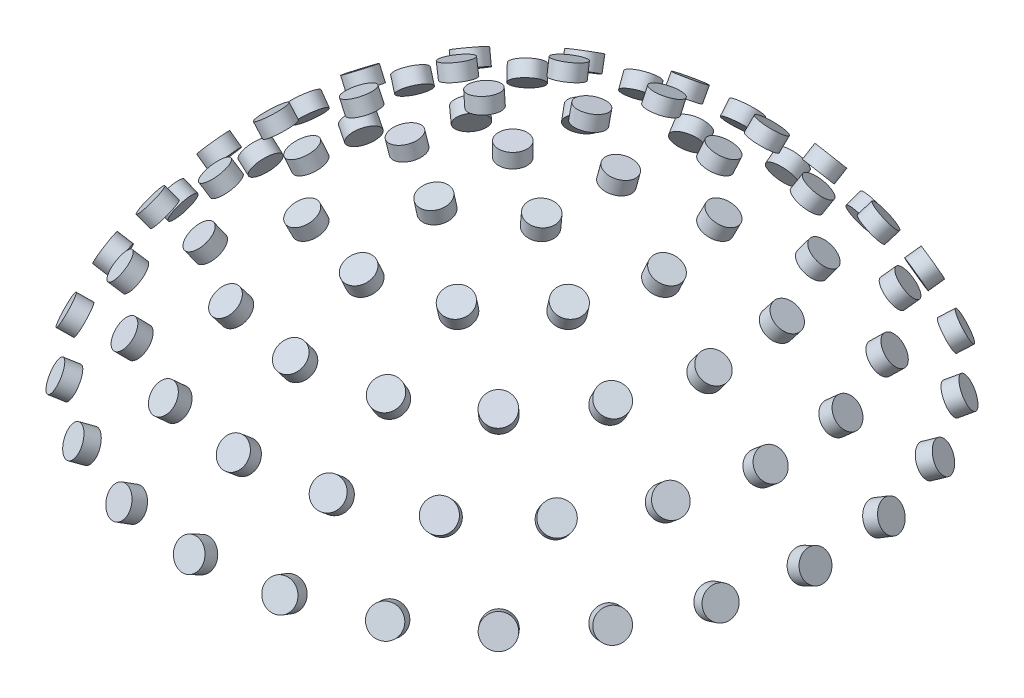
from build123d import *

# Parameters (mm, degrees)
SKETCH2_R           = 0.5
BOSS_EXTRUDE1_DEPTH = 0.5
CIRPATTERN1_COUNT   = 2
CIRPATTERN1_ANGLE   = 12.5
CIRPATTERN2_COUNT   = 2
CIRPATTERN2_ANGLE   = 25
CIRPATTERN3_COUNT   = 2
CIRPATTERN3_ANGLE   = 37.5
CIRPATTERN4_COUNT   = 2
CIRPATTERN4_ANGLE   = 50
CIRPATTERN5_COUNT   = 2
CIRPATTERN5_ANGLE   = 62.5
CIRPATTERN6_COUNT   = 6
CIRPATTERN7_COUNT   = 12
CIRPATTERN8_COUNT   = 17
CIRPATTERN9_COUNT   = 21
CIRPATTERN10_COUNT  = 25


with BuildPart() as part:
    # Sketch2 → Boss-Extrude1 (new body)
    with BuildSketch(Plane(origin=(0, 12.2, 0), x_dir=(1, 0, 0), z_dir=(0, 1, 0))):
        Circle(SKETCH2_R)
    extrude(amount=BOSS_EXTRUDE1_DEPTH)


with BuildPart() as cirpattern1_1:
    # CirPattern1: pattern copy
    add(part.part.rotate(Axis((0, 0, 0), (1, 0, 0)), 1 * CIRPATTERN1_ANGLE / (CIRPATTERN1_COUNT - 1)))


with BuildPart() as cirpattern2_1:
    # CirPattern2: pattern copy
    add(part.part.rotate(Axis((0, 0, 0), (1, 0, 0)), 1 * CIRPATTERN2_ANGLE / (CIRPATTERN2_COUNT - 1)))


with BuildPart() as cirpattern3_1:
    # CirPattern3: pattern copy
    add(part.part.rotate(Axis((0, 0, 0), (1, 0, 0)), 1 * CIRPATTERN3_ANGLE / (CIRPATTERN3_COUNT - 1)))


with BuildPart() as cirpattern4_1:
    # CirPattern4: pattern copy
    add(part.part.rotate(Axis((0, 0, 0), (1, 0, 0)), 1 * CIRPATTERN4_ANGLE / (CIRPATTERN4_COUNT - 1)))


with BuildPart() as cirpattern5_1:
    # CirPattern5: pattern copy
    add(part.part.rotate(Axis((0, 0, 0), (1, 0, 0)), 1 * CIRPATTERN5_ANGLE / (CIRPATTERN5_COUNT - 1)))


with BuildPart() as cirpattern6_1:
    # CirPattern6: pattern copy
    add(cirpattern1_1.part.rotate(Axis((0, 0, 0), (0, 1, 0)), 1 * 360 / CIRPATTERN6_COUNT))


with BuildPart() as cirpattern6_2:
    # CirPattern6: pattern copy
    add(cirpattern1_1.part.rotate(Axis((0, 0, 0), (0, 1, 0)), 2 * 360 / CIRPATTERN6_COUNT))


with BuildPart() as cirpattern6_3:
    # CirPattern6: pattern copy
    add(cirpattern1_1.part.rotate(Axis((0, 0, 0), (0, 1, 0)), 3 * 360 / CIRPATTERN6_COUNT))


with BuildPart() as cirpattern6_4:
    # CirPattern6: pattern copy
    add(cirpattern1_1.part.rotate(Axis((0, 0, 0), (0, 1, 0)), 4 * 360 / CIRPATTERN6_COUNT))


with BuildPart() as cirpattern6_5:
    # CirPattern6: pattern copy
    add(cirpattern1_1.part.rotate(Axis((0, 0, 0), (0, 1, 0)), 5 * 360 / CIRPATTERN6_COUNT))


with BuildPart() as cirpattern7_1:
    # CirPattern7: pattern copy
    add(cirpattern2_1.part.rotate(Axis((0, 0, 0), (0, 1, 0)), 1 * 360 / CIRPATTERN7_COUNT))


with BuildPart() as cirpattern7_2:
    # CirPattern7: pattern copy
    add(cirpattern2_1.part.rotate(Axis((0, 0, 0), (0, 1, 0)), 2 * 360 / CIRPATTERN7_COUNT))


with BuildPart() as cirpattern7_3:
    # CirPattern7: pattern copy
    add(cirpattern2_1.part.rotate(Axis((0, 0, 0), (0, 1, 0)), 3 * 360 / CIRPATTERN7_COUNT))


with BuildPart() as cirpattern7_4:
    # CirPattern7: pattern copy
    add(cirpattern2_1.part.rotate(Axis((0, 0, 0), (0, 1, 0)), 4 * 360 / CIRPATTERN7_COUNT))


with BuildPart() as cirpattern7_5:
    # CirPattern7: pattern copy
    add(cirpattern2_1.part.rotate(Axis((0, 0, 0), (0, 1, 0)), 5 * 360 / CIRPATTERN7_COUNT))


with BuildPart() as cirpattern7_6:
    # CirPattern7: pattern copy
    add(cirpattern2_1.part.rotate(Axis((0, 0, 0), (0, 1, 0)), 6 * 360 / CIRPATTERN7_COUNT))


with BuildPart() as cirpattern7_7:
    # CirPattern7: pattern copy
    add(cirpattern2_1.part.rotate(Axis((0, 0, 0), (0, 1, 0)), 7 * 360 / CIRPATTERN7_COUNT))


with BuildPart() as cirpattern7_8:
    # CirPattern7: pattern copy
    add(cirpattern2_1.part.rotate(Axis((0, 0, 0), (0, 1, 0)), 8 * 360 / CIRPATTERN7_COUNT))


with BuildPart() as cirpattern7_9:
    # CirPattern7: pattern copy
    add(cirpattern2_1.part.rotate(Axis((0, 0, 0), (0, 1, 0)), 9 * 360 / CIRPATTERN7_COUNT))


with BuildPart() as cirpattern7_10:
    # CirPattern7: pattern copy
    add(cirpattern2_1.part.rotate(Axis((0, 0, 0), (0, 1, 0)), 10 * 360 / CIRPATTERN7_COUNT))


with BuildPart() as cirpattern7_11:
    # CirPattern7: pattern copy
    add(cirpattern2_1.part.rotate(Axis((0, 0, 0), (0, 1, 0)), 11 * 360 / CIRPATTERN7_COUNT))


with BuildPart() as cirpattern8_1:
    # CirPattern8: pattern copy
    add(cirpattern3_1.part.rotate(Axis((0, 0, 0), (0, 1, 0)), 1 * 360 / CIRPATTERN8_COUNT))


with BuildPart() as cirpattern8_2:
    # CirPattern8: pattern copy
    add(cirpattern3_1.part.rotate(Axis((0, 0, 0), (0, 1, 0)), 2 * 360 / CIRPATTERN8_COUNT))


with BuildPart() as cirpattern8_3:
    # CirPattern8: pattern copy
    add(cirpattern3_1.part.rotate(Axis((0, 0, 0), (0, 1, 0)), 3 * 360 / CIRPATTERN8_COUNT))


with BuildPart() as cirpattern8_4:
    # CirPattern8: pattern copy
    add(cirpattern3_1.part.rotate(Axis((0, 0, 0), (0, 1, 0)), 4 * 360 / CIRPATTERN8_COUNT))


with BuildPart() as cirpattern8_5:
    # CirPattern8: pattern copy
    add(cirpattern3_1.part.rotate(Axis((0, 0, 0), (0, 1, 0)), 5 * 360 / CIRPATTERN8_COUNT))


with BuildPart() as cirpattern8_6:
    # CirPattern8: pattern copy
    add(cirpattern3_1.part.rotate(Axis((0, 0, 0), (0, 1, 0)), 6 * 360 / CIRPATTERN8_COUNT))


with BuildPart() as cirpattern8_7:
    # CirPattern8: pattern copy
    add(cirpattern3_1.part.rotate(Axis((0, 0, 0), (0, 1, 0)), 7 * 360 / CIRPATTERN8_COUNT))


with BuildPart() as cirpattern8_8:
    # CirPattern8: pattern copy
    add(cirpattern3_1.part.rotate(Axis((0, 0, 0), (0, 1, 0)), 8 * 360 / CIRPATTERN8_COUNT))


with BuildPart() as cirpattern8_9:
    # CirPattern8: pattern copy
    add(cirpattern3_1.part.rotate(Axis((0, 0, 0), (0, 1, 0)), 9 * 360 / CIRPATTERN8_COUNT))


with BuildPart() as cirpattern8_10:
    # CirPattern8: pattern copy
    add(cirpattern3_1.part.rotate(Axis((0, 0, 0), (0, 1, 0)), 10 * 360 / CIRPATTERN8_COUNT))


with BuildPart() as cirpattern8_11:
    # CirPattern8: pattern copy
    add(cirpattern3_1.part.rotate(Axis((0, 0, 0), (0, 1, 0)), 11 * 360 / CIRPATTERN8_COUNT))


with BuildPart() as cirpattern8_12:
    # CirPattern8: pattern copy
    add(cirpattern3_1.part.rotate(Axis((0, 0, 0), (0, 1, 0)), 12 * 360 / CIRPATTERN8_COUNT))


with BuildPart() as cirpattern8_13:
    # CirPattern8: pattern copy
    add(cirpattern3_1.part.rotate(Axis((0, 0, 0), (0, 1, 0)), 13 * 360 / CIRPATTERN8_COUNT))


with BuildPart() as cirpattern8_14:
    # CirPattern8: pattern copy
    add(cirpattern3_1.part.rotate(Axis((0, 0, 0), (0, 1, 0)), 14 * 360 / CIRPATTERN8_COUNT))


with BuildPart() as cirpattern8_15:
    # CirPattern8: pattern copy
    add(cirpattern3_1.part.rotate(Axis((0, 0, 0), (0, 1, 0)), 15 * 360 / CIRPATTERN8_COUNT))


with BuildPart() as cirpattern8_16:
    # CirPattern8: pattern copy
    add(cirpattern3_1.part.rotate(Axis((0, 0, 0), (0, 1, 0)), 16 * 360 / CIRPATTERN8_COUNT))


with BuildPart() as cirpattern9_1:
    # CirPattern9: pattern copy
    add(cirpattern4_1.part.rotate(Axis((0, 0, 0), (0, 1, 0)), 1 * 360 / CIRPATTERN9_COUNT))


with BuildPart() as cirpattern9_2:
    # CirPattern9: pattern copy
    add(cirpattern4_1.part.rotate(Axis((0, 0, 0), (0, 1, 0)), 2 * 360 / CIRPATTERN9_COUNT))


with BuildPart() as cirpattern9_3:
    # CirPattern9: pattern copy
    add(cirpattern4_1.part.rotate(Axis((0, 0, 0), (0, 1, 0)), 3 * 360 / CIRPATTERN9_COUNT))


with BuildPart() as cirpattern9_4:
    # CirPattern9: pattern copy
    add(cirpattern4_1.part.rotate(Axis((0, 0, 0), (0, 1, 0)), 4 * 360 / CIRPATTERN9_COUNT))


with BuildPart() as cirpattern9_5:
    # CirPattern9: pattern copy
    add(cirpattern4_1.part.rotate(Axis((0, 0, 0), (0, 1, 0)), 5 * 360 / CIRPATTERN9_COUNT))


with BuildPart() as cirpattern9_6:
    # CirPattern9: pattern copy
    add(cirpattern4_1.part.rotate(Axis((0, 0, 0), (0, 1, 0)), 6 * 360 / CIRPATTERN9_COUNT))


with BuildPart() as cirpattern9_7:
    # CirPattern9: pattern copy
    add(cirpattern4_1.part.rotate(Axis((0, 0, 0), (0, 1, 0)), 7 * 360 / CIRPATTERN9_COUNT))


with BuildPart() as cirpattern9_8:
    # CirPattern9: pattern copy
    add(cirpattern4_1.part.rotate(Axis((0, 0, 0), (0, 1, 0)), 8 * 360 / CIRPATTERN9_COUNT))


with BuildPart() as cirpattern9_9:
    # CirPattern9: pattern copy
    add(cirpattern4_1.part.rotate(Axis((0, 0, 0), (0, 1, 0)), 9 * 360 / CIRPATTERN9_COUNT))


with BuildPart() as cirpattern9_10:
    # CirPattern9: pattern copy
    add(cirpattern4_1.part.rotate(Axis((0, 0, 0), (0, 1, 0)), 10 * 360 / CIRPATTERN9_COUNT))


with BuildPart() as cirpattern9_11:
    # CirPattern9: pattern copy
    add(cirpattern4_1.part.rotate(Axis((0, 0, 0), (0, 1, 0)), 11 * 360 / CIRPATTERN9_COUNT))


with BuildPart() as cirpattern9_12:
    # CirPattern9: pattern copy
    add(cirpattern4_1.part.rotate(Axis((0, 0, 0), (0, 1, 0)), 12 * 360 / CIRPATTERN9_COUNT))


with BuildPart() as cirpattern9_13:
    # CirPattern9: pattern copy
    add(cirpattern4_1.part.rotate(Axis((0, 0, 0), (0, 1, 0)), 13 * 360 / CIRPATTERN9_COUNT))


with BuildPart() as cirpattern9_14:
    # CirPattern9: pattern copy
    add(cirpattern4_1.part.rotate(Axis((0, 0, 0), (0, 1, 0)), 14 * 360 / CIRPATTERN9_COUNT))


with BuildPart() as cirpattern9_15:
    # CirPattern9: pattern copy
    add(cirpattern4_1.part.rotate(Axis((0, 0, 0), (0, 1, 0)), 15 * 360 / CIRPATTERN9_COUNT))


with BuildPart() as cirpattern9_16:
    # CirPattern9: pattern copy
    add(cirpattern4_1.part.rotate(Axis((0, 0, 0), (0, 1, 0)), 16 * 360 / CIRPATTERN9_COUNT))


with BuildPart() as cirpattern9_17:
    # CirPattern9: pattern copy
    add(cirpattern4_1.part.rotate(Axis((0, 0, 0), (0, 1, 0)), 17 * 360 / CIRPATTERN9_COUNT))


with BuildPart() as cirpattern9_18:
    # CirPattern9: pattern copy
    add(cirpattern4_1.part.rotate(Axis((0, 0, 0), (0, 1, 0)), 18 * 360 / CIRPATTERN9_COUNT))


with BuildPart() as cirpattern9_19:
    # CirPattern9: pattern copy
    add(cirpattern4_1.part.rotate(Axis((0, 0, 0), (0, 1, 0)), 19 * 360 / CIRPATTERN9_COUNT))


with BuildPart() as cirpattern9_20:
    # CirPattern9: pattern copy
    add(cirpattern4_1.part.rotate(Axis((0, 0, 0), (0, 1, 0)), 20 * 360 / CIRPATTERN9_COUNT))


with BuildPart() as cirpattern10_1:
    # CirPattern10: pattern copy
    add(cirpattern5_1.part.rotate(Axis((0, 0, 0), (0, 1, 0)), 1 * 360 / CIRPATTERN10_COUNT))


with BuildPart() as cirpattern10_2:
    # CirPattern10: pattern copy
    add(cirpattern5_1.part.rotate(Axis((0, 0, 0), (0, 1, 0)), 2 * 360 / CIRPATTERN10_COUNT))


with BuildPart() as cirpattern10_3:
    # CirPattern10: pattern copy
    add(cirpattern5_1.part.rotate(Axis((0, 0, 0), (0, 1, 0)), 3 * 360 / CIRPATTERN10_COUNT))


with BuildPart() as cirpattern10_4:
    # CirPattern10: pattern copy
    add(cirpattern5_1.part.rotate(Axis((0, 0, 0), (0, 1, 0)), 4 * 360 / CIRPATTERN10_COUNT))


with BuildPart() as cirpattern10_5:
    # CirPattern10: pattern copy
    add(cirpattern5_1.part.rotate(Axis((0, 0, 0), (0, 1, 0)), 5 * 360 / CIRPATTERN10_COUNT))


with BuildPart() as cirpattern10_6:
    # CirPattern10: pattern copy
    add(cirpattern5_1.part.rotate(Axis((0, 0, 0), (0, 1, 0)), 6 * 360 / CIRPATTERN10_COUNT))


with BuildPart() as cirpattern10_7:
    # CirPattern10: pattern copy
    add(cirpattern5_1.part.rotate(Axis((0, 0, 0), (0, 1, 0)), 7 * 360 / CIRPATTERN10_COUNT))


with BuildPart() as cirpattern10_8:
    # CirPattern10: pattern copy
    add(cirpattern5_1.part.rotate(Axis((0, 0, 0), (0, 1, 0)), 8 * 360 / CIRPATTERN10_COUNT))


with BuildPart() as cirpattern10_9:
    # CirPattern10: pattern copy
    add(cirpattern5_1.part.rotate(Axis((0, 0, 0), (0, 1, 0)), 9 * 360 / CIRPATTERN10_COUNT))


with BuildPart() as cirpattern10_10:
    # CirPattern10: pattern copy
    add(cirpattern5_1.part.rotate(Axis((0, 0, 0), (0, 1, 0)), 10 * 360 / CIRPATTERN10_COUNT))


with BuildPart() as cirpattern10_11:
    # CirPattern10: pattern copy
    add(cirpattern5_1.part.rotate(Axis((0, 0, 0), (0, 1, 0)), 11 * 360 / CIRPATTERN10_COUNT))


with BuildPart() as cirpattern10_12:
    # CirPattern10: pattern copy
    add(cirpattern5_1.part.rotate(Axis((0, 0, 0), (0, 1, 0)), 12 * 360 / CIRPATTERN10_COUNT))


with BuildPart() as cirpattern10_13:
    # CirPattern10: pattern copy
    add(cirpattern5_1.part.rotate(Axis((0, 0, 0), (0, 1, 0)), 13 * 360 / CIRPATTERN10_COUNT))


with BuildPart() as cirpattern10_14:
    # CirPattern10: pattern copy
    add(cirpattern5_1.part.rotate(Axis((0, 0, 0), (0, 1, 0)), 14 * 360 / CIRPATTERN10_COUNT))


with BuildPart() as cirpattern10_15:
    # CirPattern10: pattern copy
    add(cirpattern5_1.part.rotate(Axis((0, 0, 0), (0, 1, 0)), 15 * 360 / CIRPATTERN10_COUNT))


with BuildPart() as cirpattern10_16:
    # CirPattern10: pattern copy
    add(cirpattern5_1.part.rotate(Axis((0, 0, 0), (0, 1, 0)), 16 * 360 / CIRPATTERN10_COUNT))


with BuildPart() as cirpattern10_17:
    # CirPattern10: pattern copy
    add(cirpattern5_1.part.rotate(Axis((0, 0, 0), (0, 1, 0)), 17 * 360 / CIRPATTERN10_COUNT))


with BuildPart() as cirpattern10_18:
    # CirPattern10: pattern copy
    add(cirpattern5_1.part.rotate(Axis((0, 0, 0), (0, 1, 0)), 18 * 360 / CIRPATTERN10_COUNT))


with BuildPart() as cirpattern10_19:
    # CirPattern10: pattern copy
    add(cirpattern5_1.part.rotate(Axis((0, 0, 0), (0, 1, 0)), 19 * 360 / CIRPATTERN10_COUNT))


with BuildPart() as cirpattern10_20:
    # CirPattern10: pattern copy
    add(cirpattern5_1.part.rotate(Axis((0, 0, 0), (0, 1, 0)), 20 * 360 / CIRPATTERN10_COUNT))


with BuildPart() as cirpattern10_21:
    # CirPattern10: pattern copy
    add(cirpattern5_1.part.rotate(Axis((0, 0, 0), (0, 1, 0)), 21 * 360 / CIRPATTERN10_COUNT))


with BuildPart() as cirpattern10_22:
    # CirPattern10: pattern copy
    add(cirpattern5_1.part.rotate(Axis((0, 0, 0), (0, 1, 0)), 22 * 360 / CIRPATTERN10_COUNT))


with BuildPart() as cirpattern10_23:
    # CirPattern10: pattern copy
    add(cirpattern5_1.part.rotate(Axis((0, 0, 0), (0, 1, 0)), 23 * 360 / CIRPATTERN10_COUNT))


with BuildPart() as cirpattern10_24:
    # CirPattern10: pattern copy
    add(cirpattern5_1.part.rotate(Axis((0, 0, 0), (0, 1, 0)), 24 * 360 / CIRPATTERN10_COUNT))


solid = Compound([part.part, cirpattern1_1.part, cirpattern2_1.part, cirpattern3_1.part, cirpattern4_1.part, cirpattern5_1.part, cirpattern6_1.part, cirpattern6_2.part, cirpattern6_3.part, cirpattern6_4.part, cirpattern6_5.part, cirpattern7_1.part, cirpattern7_2.part, cirpattern7_3.part, cirpattern7_4.part, cirpattern7_5.part, cirpattern7_6.part, cirpattern7_7.part, cirpattern7_8.part, cirpattern7_9.part, cirpattern7_10.part, cirpattern7_11.part, cirpattern8_1.part, cirpattern8_2.part, cirpattern8_3.part, cirpattern8_4.part, cirpattern8_5.part, cirpattern8_6.part, cirpattern8_7.part, cirpattern8_8.part, cirpattern8_9.part, cirpattern8_10.part, cirpattern8_11.part, cirpattern8_12.part, cirpattern8_13.part, cirpattern8_14.part, cirpattern8_15.part, cirpattern8_16.part, cirpattern9_1.part, cirpattern9_2.part, cirpattern9_3.part, cirpattern9_4.part, cirpattern9_5.part, cirpattern9_6.part, cirpattern9_7.part, cirpattern9_8.part, cirpattern9_9.part, cirpattern9_10.part, cirpattern9_11.part, cirpattern9_12.part, cirpattern9_13.part, cirpattern9_14.part, cirpattern9_15.part, cirpattern9_16.part, cirpattern9_17.part, cirpattern9_18.part, cirpattern9_19.part, cirpattern9_20.part, cirpattern10_1.part, cirpattern10_2.part, cirpattern10_3.part, cirpattern10_4.part, cirpattern10_5.part, cirpattern10_6.part, cirpattern10_7.part, cirpattern10_8.part, cirpattern10_9.part, cirpattern10_10.part, cirpattern10_11.part, cirpattern10_12.part, cirpattern10_13.part, cirpattern10_14.part, cirpattern10_15.part, cirpattern10_16.part, cirpattern10_17.part, cirpattern10_18.part, cirpattern10_19.part, cirpattern10_20.part, cirpattern10_21.part, cirpattern10_22.part, cirpattern10_23.part, cirpattern10_24.part])
